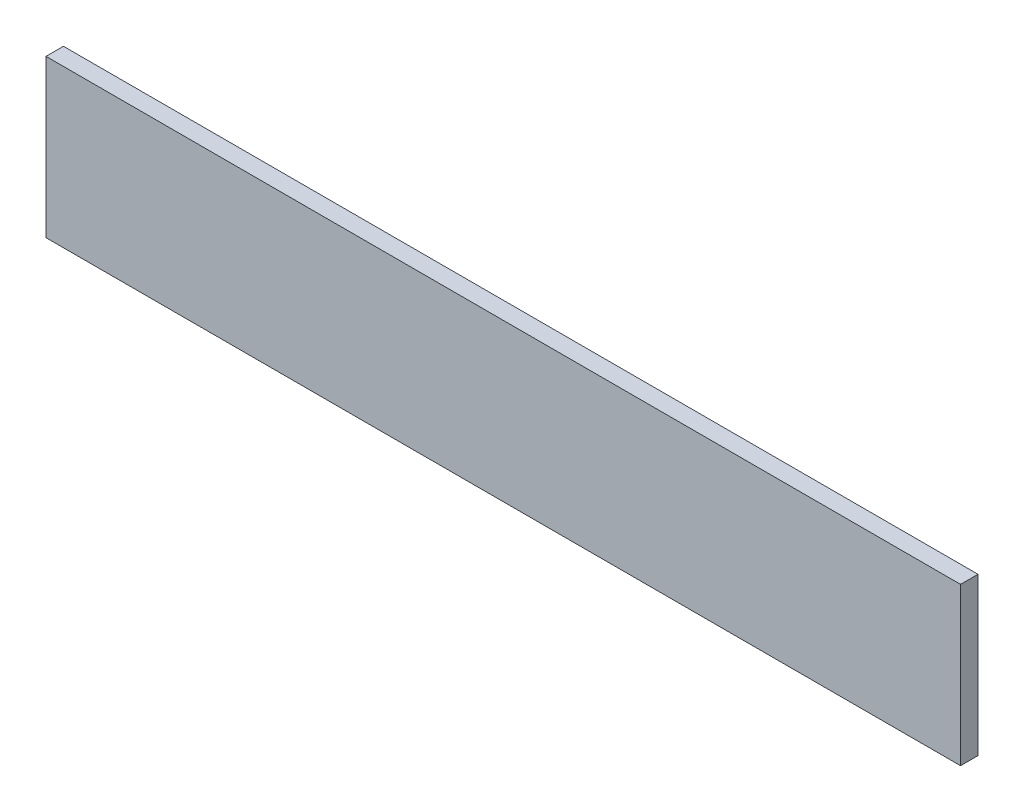
from build123d import *

# Parameters (mm, degrees)
ESQUISSE1_W        = 262
ESQUISSE1_H        = 45
BOSS_EXTRU_1_DEPTH = 5


with BuildPart() as part:
    # Esquisse1 → Boss.-Extru.1 (new body)
    with BuildSketch(Plane.XY):
        with Locations((131, 22.5)):
            Rectangle(ESQUISSE1_W, ESQUISSE1_H)
    extrude(amount=BOSS_EXTRU_1_DEPTH)


solid = part.part
